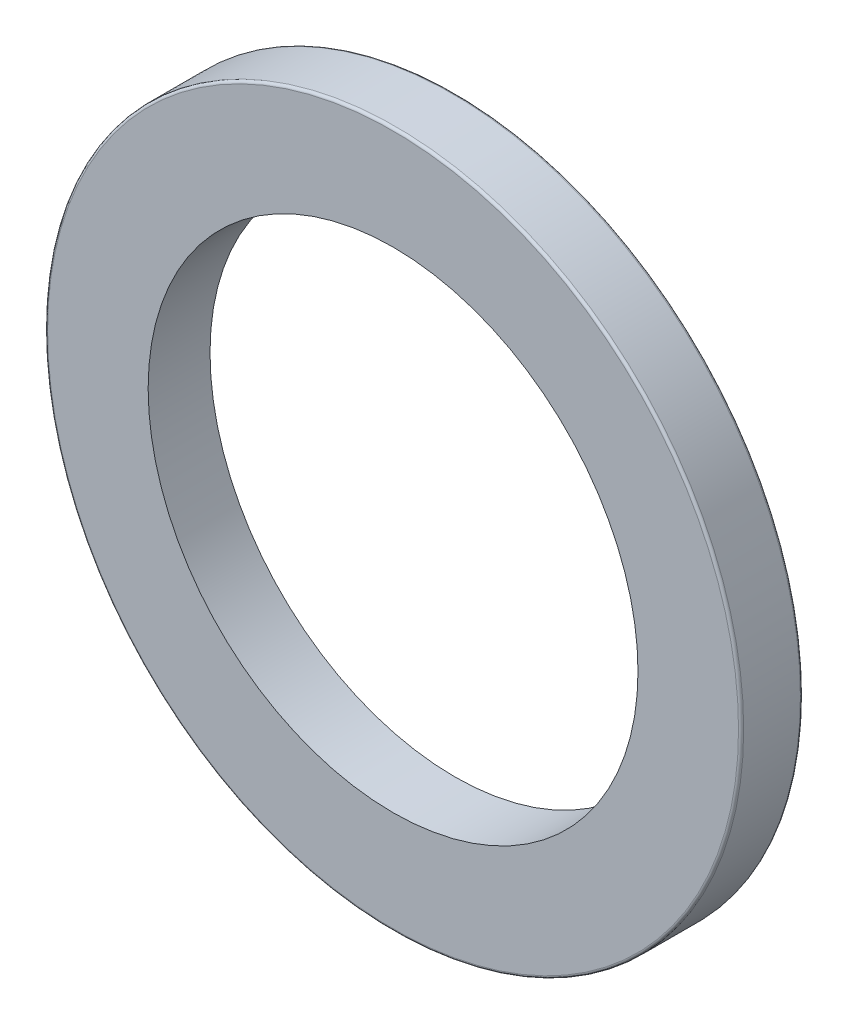
from build123d import *

# Parameters (mm, degrees)
ESQUISSE1_R        = 67.5
ESQUISSE1_R_2      = 47.5
BOSS_EXTRU_1_DEPTH = 12
CONG_1_R           = 0.5


with BuildPart() as part:
    # Esquisse1 → Boss.-Extru.1 (new body)
    with BuildSketch(Plane.XY):
        Circle(ESQUISSE1_R)
        Circle(ESQUISSE1_R_2, mode=Mode.SUBTRACT)
    extrude(amount=BOSS_EXTRU_1_DEPTH)

    # Congé1
    cong_1_edges = [part.edges().sort_by_distance(p)[0] for p in [
        (-67.5, 0, 0),
        (-67.5, 0, 12),
    ]]
    fillet(cong_1_edges, radius=CONG_1_R)


solid = part.part
